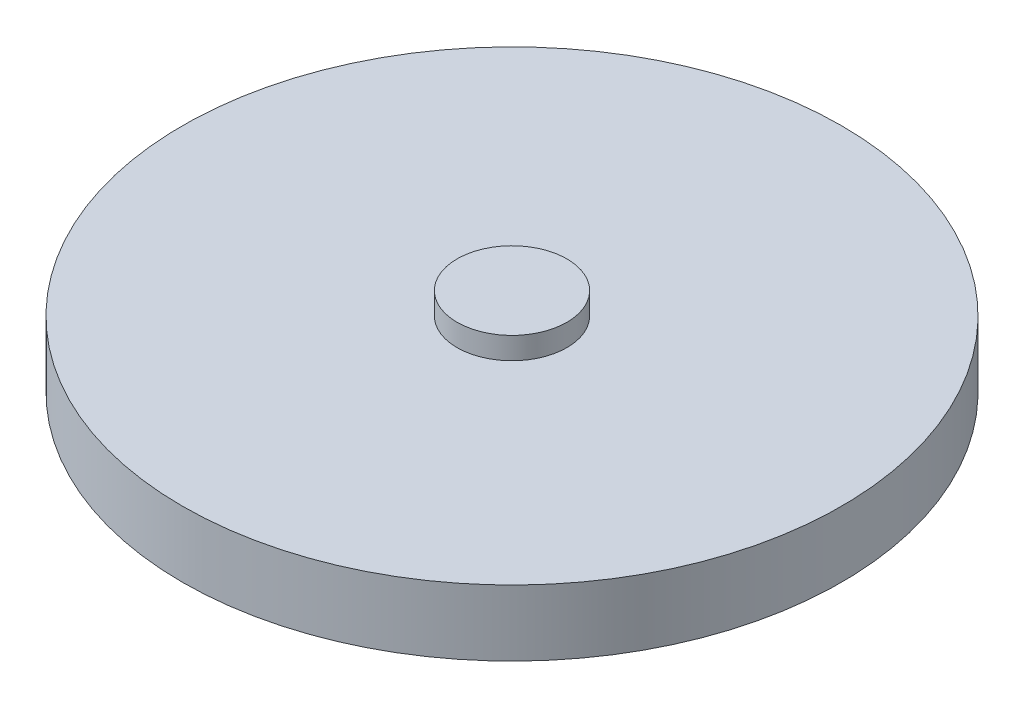
from build123d import *

# Parameters (mm, degrees)
SZKIC2_R                    = 150
DODANIE_WYCI_GNI_CIE1_DEPTH = 30
SZKIC3_R                    = 25
DODANIE_WYCI_GNI_CIE2_DEPTH = 10
SZKIC5_R                    = 17.5
WYTNIJ_WYCI_GNI_CIE1_DEPTH  = 3


with BuildPart() as part:
    # Szkic2 → Dodanie-wyciągnięcie1 (new body)
    with BuildSketch(Plane(origin=(0, 0, 0), x_dir=(1, 0, 0), z_dir=(0, 1, 0))):
        Circle(SZKIC2_R)
    extrude(amount=DODANIE_WYCI_GNI_CIE1_DEPTH)

    # Szkic3 → Dodanie-wyciągnięcie2 (add)
    with BuildSketch(Plane(origin=(0, 30, 0), x_dir=(1, 0, 0), z_dir=(0, 1, 0))):
        Circle(SZKIC3_R)
    extrude(amount=DODANIE_WYCI_GNI_CIE2_DEPTH)

    # Szkic5 → Wytnij-wyciągnięcie1 (cut)
    with BuildSketch(Plane(origin=(0, 0, 0), x_dir=(-1, 0, 0), z_dir=(0, -1, 0))):
        Circle(SZKIC5_R)
    extrude(amount=-WYTNIJ_WYCI_GNI_CIE1_DEPTH, mode=Mode.SUBTRACT)


solid = part.part
